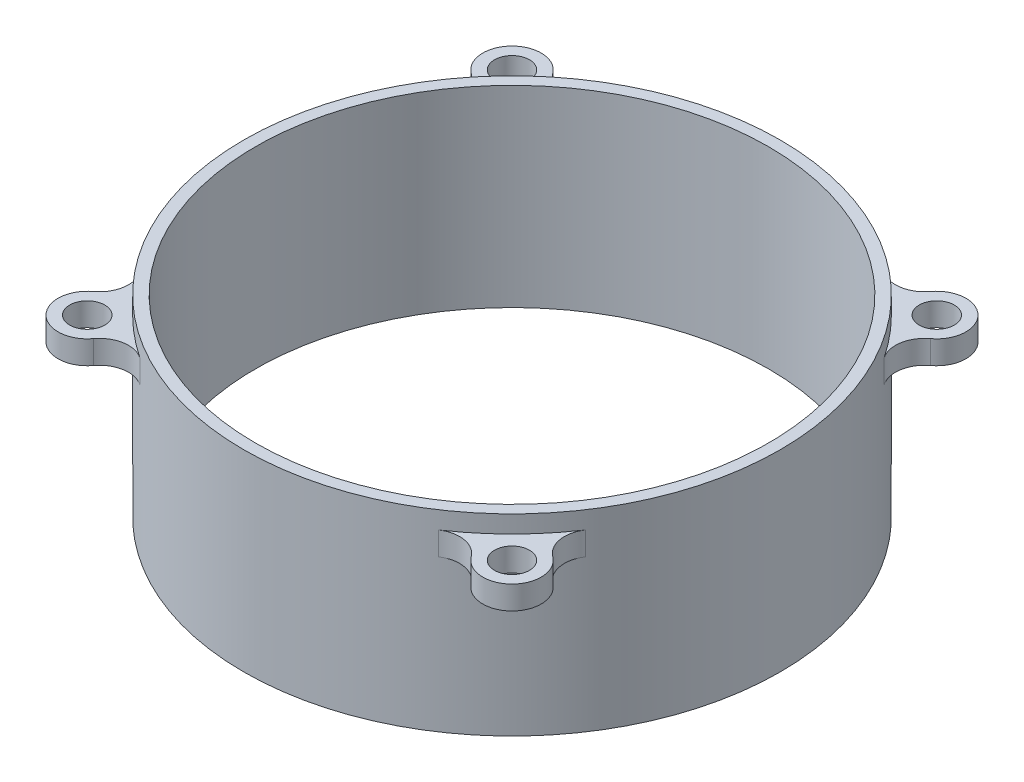
from build123d import *

# Parameters (mm, degrees)
SKETCH_2_R          = 1.5
CUT_EXTRUDE_1_DEPTH = 16
SKETCH_4_OUTSIDE_W  = 74.818
SKETCH_4_OUTSIDE_H  = 74.818
CUT_EXTRUDE_3_DEPTH = 16


with BuildPart() as part:
    # 草图1 → 旋转1 (revolve)
    with BuildSketch(Plane.XY):
        Polygon((22, 1.5), (22, -15), (23, -15), (23, -2), (28.25, -2), (28.25, 0), (23, 0), (23, 1.5), align=None)
    revolve(axis=Axis((0, 0, 0), (0, 1, 0)))

    # 草图2 → 切除-拉伸1 (cut, through all)
    with BuildSketch(Plane(origin=(0, 0, 0), x_dir=(1, 0, 0), z_dir=(0, 1, 0))):
        with Locations((-18.207999616, 18.207999616)):
            Circle(SKETCH_2_R)
        with Locations((18.207999616, 18.207999616)):
            Circle(SKETCH_2_R)
        with Locations((18.207999616, -18.207999616)):
            Circle(SKETCH_2_R)
        with Locations((-18.207999616, -18.207999616)):
            Circle(SKETCH_2_R)
    extrude(amount=-CUT_EXTRUDE_1_DEPTH, mode=Mode.SUBTRACT)

    # 草图4 outside → 切除-拉伸3 (cut, through all)
    with BuildSketch(Plane(origin=(0, 0, 0), x_dir=(1, 0, 0), z_dir=(0, 1, 0))):
        Rectangle(SKETCH_4_OUTSIDE_W, SKETCH_4_OUTSIDE_H)
        with BuildLine():
            ThreePointArc((-16.199808887, 19.697016069), (-19.975766569, 19.975766569), (-19.697016069, 16.199808887))
            ThreePointArc((-19.697016069, 16.199808887), (-18.722615608, 14.617736813), (-19.10897051, 12.800283045))
            ThreePointArc((-19.10897051, 12.800283045), (-23, 0), (-19.10897051, -12.800283045))
            ThreePointArc((-19.10897051, -12.800283045), (-18.722615608, -14.617736813), (-19.697016069, -16.199808887))
            ThreePointArc((-19.697016069, -16.199808887), (-19.975766569, -19.975766569), (-16.199808887, -19.697016069))
            ThreePointArc((-16.199808887, -19.697016069), (-14.617736813, -18.722615608), (-12.800283045, -19.10897051))
            ThreePointArc((-12.800283045, -19.10897051), (0, -23), (12.800283045, -19.10897051))
            ThreePointArc((12.800283045, -19.10897051), (14.617736813, -18.722615608), (16.199808887, -19.697016069))
            ThreePointArc((16.199808887, -19.697016069), (19.975766569, -19.975766569), (19.697016069, -16.199808887))
            ThreePointArc((19.697016069, -16.199808887), (18.722615608, -14.617736813), (19.10897051, -12.800283045))
            ThreePointArc((19.10897051, -12.800283045), (23, 0), (19.10897051, 12.800283045))
            ThreePointArc((19.10897051, 12.800283045), (18.722615608, 14.617736813), (19.697016069, 16.199808887))
            ThreePointArc((19.697016069, 16.199808887), (19.975766569, 19.975766569), (16.199808887, 19.697016069))
            ThreePointArc((16.199808887, 19.697016069), (14.617736813, 18.722615608), (12.800283045, 19.10897051))
            ThreePointArc((12.800283045, 19.10897051), (0, 23), (-12.800283045, 19.10897051))
            ThreePointArc((-12.800283045, 19.10897051), (-14.617736813, 18.722615608), (-16.199808887, 19.697016069))
        make_face(mode=Mode.SUBTRACT)
    extrude(amount=-CUT_EXTRUDE_3_DEPTH, mode=Mode.SUBTRACT)


solid = part.part
